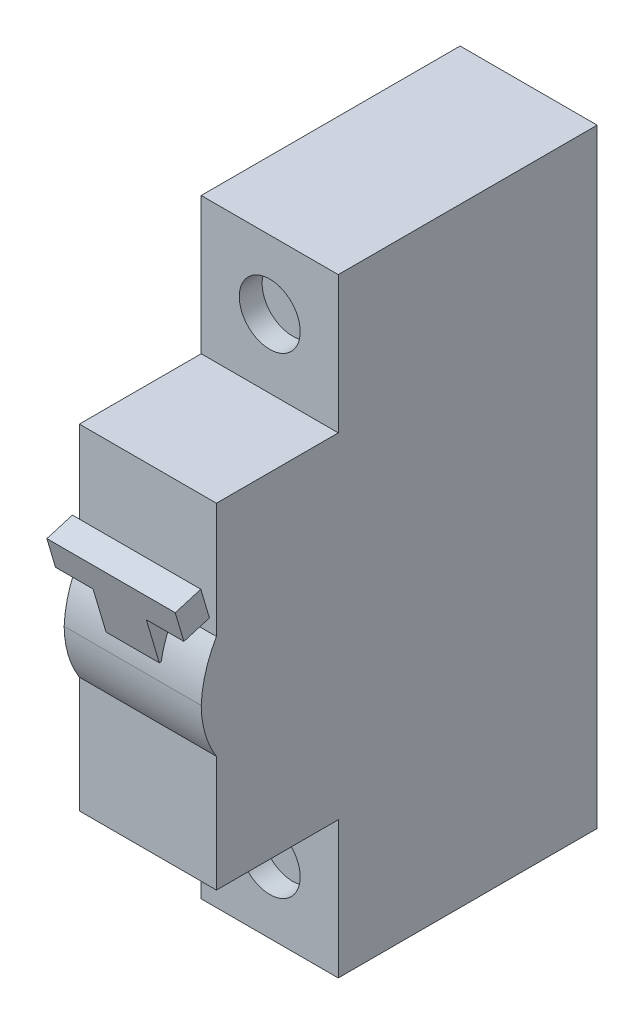
from build123d import *

# Parameters (mm, degrees)
CROQUIS1_W              = 18
CROQUIS1_H              = 80
SALIENTE_EXTRUIR1_DEPTH = 50
CROQUIS2_W              = 16
CROQUIS2_H              = 18
CORTAR_EXTRUIR1_DEPTH   = 25
SALIENTE_EXTRUIR2_DEPTH = 18
CROQUIS4_W              = 6.99659876
CROQUIS4_H              = 2.653687506
SALIENTE_EXTRUIR3_DEPTH = 2
CORTAR_EXTRUIR2_DEPTH   = 6.996599
CROQUIS6_W              = 6.99659876
CROQUIS6_H              = 3.5
SALIENTE_EXTRUIR4_DEPTH = 6
CROQUIS7_W              = 16.864509826
CROQUIS7_H              = 3.5
SALIENTE_EXTRUIR5_DEPTH = 4
CROQUIS8_R              = 4
CORTAR_EXTRUIR3_DEPTH   = 3


with BuildPart() as part:
    # Croquis1 → Saliente-Extruir1 (new body)
    with BuildSketch(Plane.XY):
        with Locations((9, -40)):
            Rectangle(CROQUIS1_W, CROQUIS1_H)
    extrude(amount=-SALIENTE_EXTRUIR1_DEPTH)

    # Croquis2 → Cortar-Extruir1 (cut)
    with BuildSketch(Plane.ZY):
        with Locations((-8, -9)):
            Rectangle(CROQUIS2_W, CROQUIS2_H)
        with Locations((-8, -71)):
            Rectangle(CROQUIS2_W, CROQUIS2_H)
    extrude(amount=-CORTAR_EXTRUIR1_DEPTH, mode=Mode.SUBTRACT)

    # Croquis3 → Saliente-Extruir2 (add)
    with BuildSketch(Plane.ZY):
        with BuildLine():
            Line((0, -33.158339238), (0, -46.786065604))
            ThreePointArc((0, -46.786065604), (1.471610076, -43.53202647), (2, -40))
            ThreePointArc((2, -40), (1.417568162, -36.457103303), (0, -33.158339238))
        make_face()
    extrude(amount=-SALIENTE_EXTRUIR2_DEPTH)

    # Croquis4 → Saliente-Extruir3 (add)
    with BuildSketch(Plane.XY):
        with Locations((9, -36.579169619)):
            Rectangle(CROQUIS4_W, CROQUIS4_H)
    extrude(amount=SALIENTE_EXTRUIR3_DEPTH)

    # Croquis5 → Cortar-Extruir2 (cut)
    with BuildSketch(Plane.ZY.offset(-5.50170062)):
        Polygon((2, -37.906013372), (-1.355869072, -36.911959665), (-0.421934466, -33.759049274), (2.933934606, -34.75310298), align=None)
    extrude(amount=-CORTAR_EXTRUIR2_DEPTH, mode=Mode.SUBTRACT)

    # Croquis6 → Saliente-Extruir4 (add)
    with BuildSketch(Plane(origin=(0, -34.303696532, -10.16121784), x_dir=(1, 0, 0), z_dir=(0, 0.958819735, 0.284015345))):
        with Locations((9, -10.933528924)):
            Rectangle(CROQUIS6_W, CROQUIS6_H)
    extrude(amount=SALIENTE_EXTRUIR4_DEPTH)

    # Croquis7 → Saliente-Extruir5 (add)
    with BuildSketch(Plane(origin=(0, -28.550778123, -8.457125772), x_dir=(1, 0, 0), z_dir=(0, 0.958819735, 0.284015345))):
        with Locations((9, -10.933528924)):
            Rectangle(CROQUIS7_W, CROQUIS7_H)
    extrude(amount=SALIENTE_EXTRUIR5_DEPTH)

    # Croquis8 → Cortar-Extruir3 (cut)
    with BuildSketch(Plane.XY.offset(-16)):
        with Locations((9, -9)):
            Circle(CROQUIS8_R)
        with Locations((9, -71)):
            Circle(CROQUIS8_R)
    extrude(amount=-CORTAR_EXTRUIR3_DEPTH, mode=Mode.SUBTRACT)


solid = part.part
